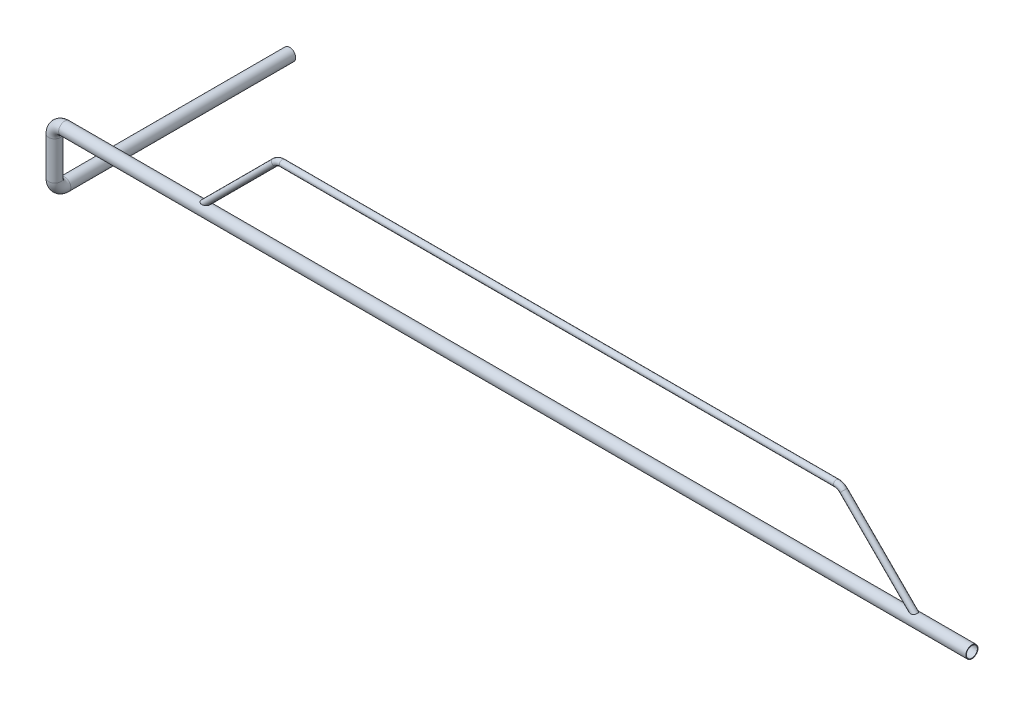
from build123d import *

# Parameters (mm, degrees)
SWEEP_THIN1_PROFILE_R   = 30
SWEEP_THIN1_PROFILE_R_2 = 27
SWEEP_THIN2_PROFILE_R   = 15
SWEEP_THIN2_PROFILE_R_2 = 12


with BuildPart() as part:
    # Sweep-Thin1: sweep along a curve in space
    with BuildLine() as sweep_thin1_path:
        Line((-24895.392811232, -8331.387423111, 39894.90333253), (-29366.557683291, -8331.387423111, 39894.90333253))
        ThreePointArc((-29416.557683291, -8381.387423111, 39894.90333253), (-29401.913022351, -8346.032084052, 39894.90333253), (-29366.557683291, -8331.387423111, 39894.90333253))
        Line((-29416.557683291, -8381.387423111, 39894.90333253), (-29416.557683291, -8570.228633414, 39894.90333253))
        ThreePointArc((-29416.557683291, -8620.228633414, 39844.90333253), (-29416.557683291, -8605.583972473, 39880.25867159), (-29416.557683291, -8570.228633414, 39894.90333253))
        Line((-29416.557683291, -8620.228633414, 39844.90333253), (-29416.557683291, -8620.228633414, 38736.700196057))
    # Sweep-Thin1 profile (on start of the path) → Sweep-Thin1 (sweep)
    with BuildSketch(Plane(origin=(-24895.392811232, -8331.387423111, 39894.90333253), x_dir=(0, 0, -1), z_dir=(-1, 0, 0))):
        Circle(SWEEP_THIN1_PROFILE_R)
        Circle(SWEEP_THIN1_PROFILE_R_2, mode=Mode.SUBTRACT)
    sweep(path=sweep_thin1_path.line)

    # Sweep-Thin2: sweep along a curve in space
    with BuildLine() as sweep_thin2_path:
        Line((-25155.056129062, -8331.387423111, 39894.903332533), (-25527.6898983, -7958.753653874, 39894.903332535))
        ThreePointArc((-25563.045237359, -7944.108992933, 39894.903332535), (-25543.911065741, -7947.915016308, 39894.903332536), (-25527.6898983, -7958.753653874, 39894.903332535))
        Line((-25563.045237359, -7944.108992933, 39894.903332535), (-28294.229848722, -7944.108992933, 39894.903332535))
        ThreePointArc((-28294.229848722, -7944.108992933, 39894.903332535), (-28313.364020341, -7947.915016308, 39894.903332533), (-28329.585187782, -7958.753653874, 39894.90333253))
        Line((-28329.585187782, -7958.753653874, 39894.90333253), (-28702.218957019, -8331.387423111, 39894.90333253))
    # Sweep-Thin2 profile (on start of the path) → Sweep-Thin2 (sweep)
    with BuildSketch(Plane(origin=(-25155.056129062, -8331.387423111, 39894.903332533), x_dir=(0.7071067811865518, 0.7071067811865432, 0), z_dir=(-0.7071067811865432, 0.7071067811865518, 4.556243152942441e-12))):
        Circle(SWEEP_THIN2_PROFILE_R)
        Circle(SWEEP_THIN2_PROFILE_R_2, mode=Mode.SUBTRACT)
    sweep(path=sweep_thin2_path.line)


solid = part.part
